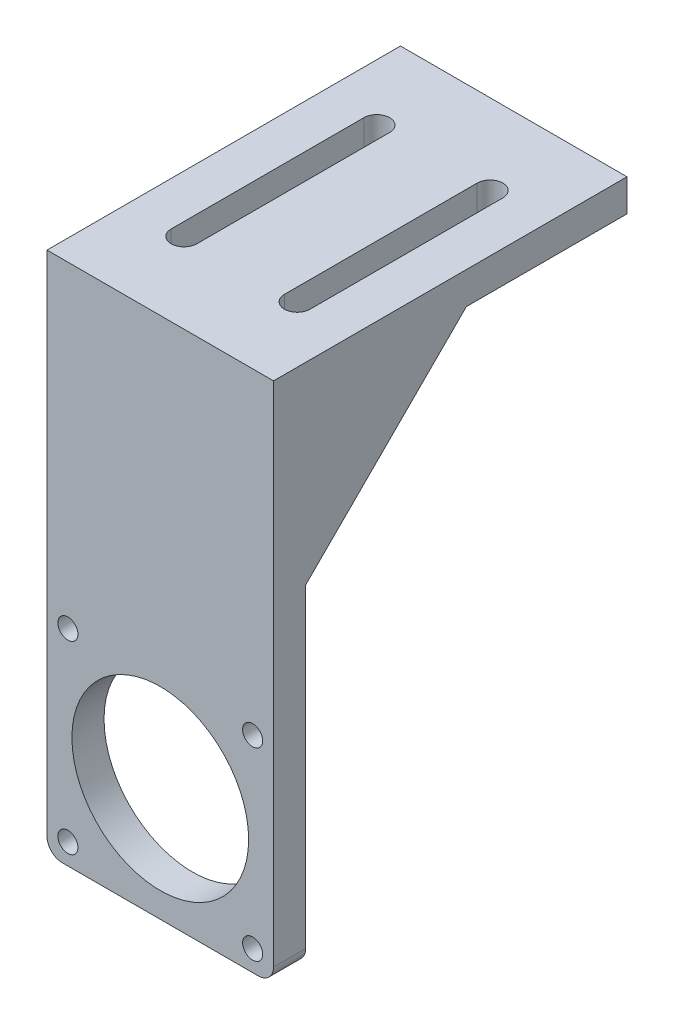
from build123d import *

# Parameters (mm, degrees)
SKETCH_1_R      = 1.25
SKETCH_1_R_2    = 11
EXTRUDE_1_DEPTH = 4
SKETCH_2_W      = 28.2
SKETCH_2_H      = 4
SKETCH_2_H_2    = 40
EXTRUDE_2_DEPTH = 4
EXTRUDE_3_DEPTH = 2


with BuildPart() as part:
    # 草图1 → 凸台-拉伸1 (new body)
    with BuildSketch(Plane.XY):
        with BuildLine():
            Line((14.449257035, -14.332751245), (14.449257035, 44.867089431))
            Line((14.449257035, 44.867089431), (-13.750742965, 44.867089431))
            Line((-13.750742965, 44.867089431), (-13.750742965, -14.332751245))
            ThreePointArc((-13.750742965, -14.332751245), (-13.194199184, -15.676366788), (-11.850583641, -16.232910569))
            Line((-11.850583641, -16.232910569), (0.349257035, -16.232910569))
            Line((0.349257035, -16.232910569), (12.549097711, -16.232910569))
            ThreePointArc((12.549097711, -16.232910569), (13.892713254, -15.676366788), (14.449257035, -14.332751245))
        make_face()
        with Locations((-11.150742965, 9.367089431)):
            Circle(SKETCH_1_R, mode=Mode.SUBTRACT)
        with Locations((11.849257035, 9.367089431)):
            Circle(SKETCH_1_R, mode=Mode.SUBTRACT)
        with Locations((-11.150742965, -13.632910569)):
            Circle(SKETCH_1_R, mode=Mode.SUBTRACT)
        with Locations((11.849257035, -13.632910569)):
            Circle(SKETCH_1_R, mode=Mode.SUBTRACT)
        with Locations((0.349257035, -2.132910569)):
            Circle(SKETCH_1_R_2, mode=Mode.SUBTRACT)
    extrude(amount=EXTRUDE_1_DEPTH)

    # 草图2 → 凸台-拉伸2 (add)
    with BuildSketch(Plane(origin=(0, 44.867089431, 0), x_dir=(1, 0, 0), z_dir=(0, 1, 0))):
        with Locations((0.349257035, -2)):
            Rectangle(SKETCH_2_W, SKETCH_2_H)
        with Locations((0.349257035, 20)):
            Rectangle(SKETCH_2_W, SKETCH_2_H_2)
        with BuildLine():
            ThreePointArc((-5.100742965, 6), (-6.700742965, 4.4), (-8.300742965, 6))
            Line((-8.300742965, 6), (-8.300742965, 30))
            ThreePointArc((-8.300742965, 30), (-6.700742965, 31.6), (-5.100742965, 30))
            Line((-5.100742965, 30), (-5.100742965, 6))
        make_face(mode=Mode.SUBTRACT)
        with BuildLine():
            ThreePointArc((8.999257035, 6), (7.399257035, 4.4), (5.799257035, 6))
            Line((5.799257035, 6), (5.799257035, 30))
            ThreePointArc((5.799257035, 30), (7.399257035, 31.6), (8.999257035, 30))
            Line((8.999257035, 30), (8.999257035, 6))
        make_face(mode=Mode.SUBTRACT)
    extrude(amount=EXTRUDE_2_DEPTH)

    # 草图3 → 凸台-拉伸3 (add)
    with BuildSketch(Plane(origin=(14.449257035, 0, 0), x_dir=(0, 0, -1), z_dir=(1, 0, 0))):
        Polygon((20, 44.867089431), (0, 44.867089431), (0, 24.867089431), align=None)
    extrude_3 = extrude(amount=-EXTRUDE_3_DEPTH)

    # 镜向2: 凸台-拉伸3 across plane
    add(extrude_3.mirror(Plane(origin=(0.349257035, 0, 0), x_dir=(0, 0, 1), z_dir=(1, 0, 0))))


solid = part.part
